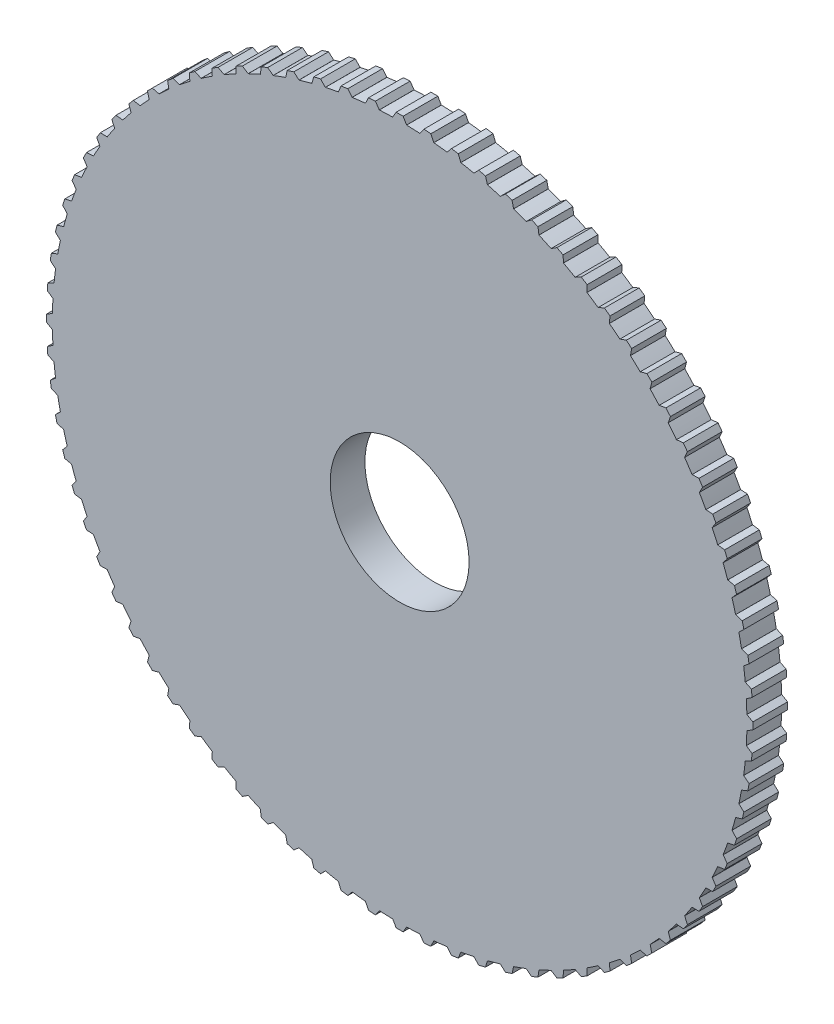
from build123d import *

# Parameters (mm, degrees)
SKETCH1_R           = 20
BOSS_EXTRUDE1_DEPTH = 10


with BuildPart() as part:
    # Sketch1 → Boss-Extrude1 (new body)
    with BuildSketch(Plane.XY):
        with BuildLine():
            Line((-1e-09, 101.7), (0.999999999, 101.7))
            Line((0.999999999, 101.7), (1.999999999, 100))
            Line((1.999999999, 100), (1.999600119, 99.980005998))
            ThreePointArc((1.999600119, 99.980005998), (3.925981575, 99.922903624), (5.85090484, 99.828687823))
            Line((5.85090484, 99.828687823), (5.852074904, 99.848651565))
            Line((5.852074904, 99.848651565), (6.982372701, 101.464951936))
            Line((6.982372701, 101.464951936), (7.979290034, 101.386492841))
            Line((7.979290034, 101.386492841), (8.976207368, 101.308033745))
            Line((8.976207368, 101.308033745), (9.839744239, 99.534815182))
            Line((9.839744239, 99.534815182), (9.837776881, 99.514914189))
            ThreePointArc((9.837776881, 99.514914189), (11.753739745, 99.306845696), (13.665337028, 99.061892592))
            Line((13.665337028, 99.061892592), (13.668069822, 99.08170299))
            Line((13.668069822, 99.08170299), (14.921696753, 100.604338704))
            Line((14.921696753, 100.604338704), (15.909385094, 100.447904239))
            Line((15.909385094, 100.447904239), (16.897073434, 100.291469774))
            Line((16.897073434, 100.291469774), (17.618823184, 98.45596513))
            Line((17.618823184, 98.45596513), (17.615300476, 98.436279842))
            ThreePointArc((17.615300476, 98.436279842), (19.509032201, 98.078528041), (21.395517868, 97.684347851))
            Line((21.395517868, 97.684347851), (21.399796544, 97.703882768))
            Line((21.399796544, 97.703882768), (22.769023583, 99.123466268))
            Line((22.769023583, 99.123466268), (23.741393503, 98.890020905))
            Line((23.741393503, 98.890020905), (24.713763423, 98.656575541))
            Line((24.713763423, 98.656575541), (25.289276225, 96.770101312))
            Line((25.289276225, 96.770101312), (25.284219887, 96.750753096))
            ThreePointArc((25.284219887, 96.750753096), (27.144044985, 96.245523646), (28.993788226, 95.704546623))
            Line((28.993788226, 95.704546623), (28.999586404, 95.723685618))
            Line((28.999586404, 95.723685618), (30.47597181, 97.031464702))
            Line((30.47597181, 97.031464702), (31.427028327, 96.722447707))
            Line((31.427028327, 96.722447707), (32.378084843, 96.413430713))
            Line((32.378084843, 96.413430713), (32.803812469, 94.487617641))
            Line((32.803812469, 94.487617641), (32.797253674, 94.468725785))
            ThreePointArc((32.797253674, 94.468725785), (34.611705707, 93.819133593), (36.413302238, 93.13469504))
            Line((36.413302238, 93.13469504), (36.42058417, 93.153320116))
            Line((36.42058417, 93.153320116), (37.995025538, 94.341231889))
            Line((37.995025538, 94.341231889), (38.91890507, 93.958548457))
            Line((38.91890507, 93.958548457), (39.842784603, 93.575865024))
            Line((39.842784603, 93.575865024), (40.1161023, 91.622586387))
            Line((40.1161023, 91.622586387), (40.108081486, 91.604267365))
            ThreePointArc((40.108081486, 91.604267365), (41.865973753, 90.814317383), (43.608316133, 89.990637091))
            Line((43.608316133, 89.990637091), (43.617036924, 90.008633419))
            Line((43.617036924, 90.008633419), (45.279827298, 91.06935401))
            Line((45.279827298, 91.06935401), (46.170833822, 90.61536351))
            Line((46.170833822, 90.61536351), (47.061840346, 90.161373011))
            Line((47.061840346, 90.161373011), (47.181063021, 88.19267142))
            Line((47.181063021, 88.19267142), (47.171629639, 88.175038175))
            ThreePointArc((47.171629639, 88.175038175), (48.862124149, 87.249600708), (50.534470258, 86.29175694))
            Line((50.534470258, 86.29175694), (50.544576142, 86.309013565))
            Line((50.544576142, 86.309013565), (52.285463866, 87.23600328))
            Line((52.285463866, 87.23600328), (53.13810403, 86.713504715))
            Line((53.13810403, 86.713504715), (53.990744195, 86.191006151))
            Line((53.990744195, 86.191006151), (53.955136799, 84.219019306))
            Line((53.955136799, 84.219019306), (53.944349008, 84.202180554))
            ThreePointArc((53.944349008, 84.202180554), (55.557023301, 83.146961231), (57.14906257, 82.060859412))
            Line((57.14906257, 82.060859412), (57.160491239, 82.077269943))
            Line((57.160491239, 82.077269943), (58.968743163, 82.864813581))
            Line((58.968743163, 82.864813581), (59.777760157, 82.277028328))
            Line((59.777760157, 82.277028328), (60.586777151, 81.689243076))
            Line((60.586777151, 81.689243076), (60.396559217, 79.726128933))
            Line((60.396559217, 79.726128933), (60.384483528, 79.71018849))
            ThreePointArc((60.384483528, 79.71018849), (61.90939493, 78.531693089), (63.411311906, 77.324029398))
            Line((63.411311906, 77.324029398), (63.423992901, 77.339492657))
            Line((63.423992901, 77.339492657), (65.288460548, 77.98273475))
            Line((65.288460548, 77.98273475), (66.048866514, 77.333286702))
            Line((66.048866514, 77.333286702), (66.80927248, 76.683838654))
            Line((66.80927248, 76.683838654), (66.465616763, 74.741700464))
            Line((66.465616763, 74.741700464), (66.452327627, 74.726756607))
            ThreePointArc((66.452327627, 74.726756607), (67.880074552, 73.432250944), (69.282609419, 72.11047103))
            Line((69.282609419, 72.11047103), (69.296464555, 72.124891682))
            Line((69.296464555, 72.124891682), (71.205652864, 72.619866428))
            Line((71.205652864, 72.619866428), (71.912759645, 71.912759647))
            Line((71.912759645, 71.912759647), (72.619866427, 71.205652866))
            Line((72.619866427, 71.205652866), (72.12489168, 69.296464557))
            Line((72.12489168, 69.296464557), (72.110471028, 69.282609421))
            ThreePointArc((72.110471028, 69.282609421), (73.432250943, 67.880074554), (74.726756605, 66.452327628))
            Line((74.726756605, 66.452327628), (74.741700462, 66.465616765))
            Line((74.741700462, 66.465616765), (76.683838652, 66.809272481))
            Line((76.683838652, 66.809272481), (77.3332867, 66.048866516))
            Line((77.3332867, 66.048866516), (77.982734749, 65.28846055))
            Line((77.982734749, 65.28846055), (77.339492655, 63.423992903))
            Line((77.339492655, 63.423992903), (77.324029396, 63.411311908))
            ThreePointArc((77.324029396, 63.411311908), (78.531693087, 61.909394932), (79.710188488, 60.38448353))
            Line((79.710188488, 60.38448353), (79.726128932, 60.396559219))
            Line((79.726128932, 60.396559219), (81.689243074, 60.586777153))
            Line((81.689243074, 60.586777153), (82.277028327, 59.777760159))
            Line((82.277028327, 59.777760159), (82.864813579, 58.968743165))
            Line((82.864813579, 58.968743165), (82.077269941, 57.160491241))
            Line((82.077269941, 57.160491241), (82.06085941, 57.149062572))
            ThreePointArc((82.06085941, 57.149062572), (83.14696123, 55.557023303), (84.202180553, 53.94434901))
            Line((84.202180553, 53.94434901), (84.219019305, 53.955136801))
            Line((84.219019305, 53.955136801), (86.191006149, 53.990744197))
            Line((86.191006149, 53.990744197), (86.713504714, 53.138104032))
            Line((86.713504714, 53.138104032), (87.236003278, 52.285463868))
            Line((87.236003278, 52.285463868), (86.309013564, 50.544576144))
            Line((86.309013564, 50.544576144), (86.291756938, 50.53447026))
            ThreePointArc((86.291756938, 50.53447026), (87.249600707, 48.862124151), (88.175038174, 47.171629641))
            Line((88.175038174, 47.171629641), (88.192671418, 47.181063023))
            Line((88.192671418, 47.181063023), (90.161373009, 47.061840349))
            Line((90.161373009, 47.061840349), (90.615363509, 46.170833824))
            Line((90.615363509, 46.170833824), (91.069354008, 45.2798273))
            Line((91.069354008, 45.2798273), (90.008633417, 43.617036926))
            Line((90.008633417, 43.617036926), (89.99063709, 43.608316136))
            ThreePointArc((89.99063709, 43.608316136), (90.814317382, 41.865973755), (91.604267364, 40.108081488))
            Line((91.604267364, 40.108081488), (91.622586385, 40.116102302))
            Line((91.622586385, 40.116102302), (93.575865023, 39.842784605))
            Line((93.575865023, 39.842784605), (93.958548455, 38.918905073))
            Line((93.958548455, 38.918905073), (94.341231888, 37.99502554))
            Line((94.341231888, 37.99502554), (93.153320115, 36.420584172))
            Line((93.153320115, 36.420584172), (93.134695039, 36.41330224))
            ThreePointArc((93.134695039, 36.41330224), (93.819133592, 34.611705709), (94.468725784, 32.797253676))
            Line((94.468725784, 32.797253676), (94.48761764, 32.803812471))
            Line((94.48761764, 32.803812471), (96.413430712, 32.378084845))
            Line((96.413430712, 32.378084845), (96.722447706, 31.427028329))
            Line((96.722447706, 31.427028329), (97.0314647, 30.475971813))
            Line((97.0314647, 30.475971813), (95.723685617, 28.999586406))
            Line((95.723685617, 28.999586406), (95.704546622, 28.993788228))
            ThreePointArc((95.704546622, 28.993788228), (96.245523645, 27.144044988), (96.750753096, 25.284219889))
            Line((96.750753096, 25.284219889), (96.770101311, 25.289276227))
            Line((96.770101311, 25.289276227), (98.656575539, 24.713763426))
            Line((98.656575539, 24.713763426), (98.890020903, 23.741393505))
            Line((98.890020903, 23.741393505), (99.123466267, 22.769023585))
            Line((99.123466267, 22.769023585), (97.703882766, 21.399796546))
            Line((97.703882766, 21.399796546), (97.684347851, 21.39551787))
            ThreePointArc((97.684347851, 21.39551787), (98.07852804, 19.509032203), (98.436279842, 17.615300479))
            Line((98.436279842, 17.615300479), (98.455965128, 17.618823186))
            Line((98.455965128, 17.618823186), (100.291469772, 16.897073436))
            Line((100.291469772, 16.897073436), (100.447904237, 15.909385096))
            Line((100.447904237, 15.909385096), (100.604338702, 14.921696755))
            Line((100.604338702, 14.921696755), (99.081702989, 13.668069824))
            Line((99.081702989, 13.668069824), (99.061892592, 13.66533703))
            ThreePointArc((99.061892592, 13.66533703), (99.306845695, 11.753739747), (99.514914189, 9.837776883))
            Line((99.514914189, 9.837776883), (99.534815181, 9.839744241))
            Line((99.534815181, 9.839744241), (101.308033744, 8.97620737))
            Line((101.308033744, 8.97620737), (101.38649284, 7.979290037))
            Line((101.38649284, 7.979290037), (101.464951935, 6.982372703))
            Line((101.464951935, 6.982372703), (99.848651564, 5.852074907))
            Line((99.848651564, 5.852074907), (99.828687823, 5.850904843))
            ThreePointArc((99.828687823, 5.850904843), (99.922903624, 3.925981577), (99.980005998, 1.999600121))
            Line((99.980005998, 1.999600121), (99.999999999, 2.000000001))
            Line((99.999999999, 2.000000001), (101.699999999, 1.000000001))
            Line((101.699999999, 1.000000001), (101.699999999, 1e-09))
            Line((101.699999999, 1e-09), (101.699999999, -0.999999999))
            Line((101.699999999, -0.999999999), (99.999999999, -1.999999999))
            Line((99.999999999, -1.999999999), (99.980005998, -1.999600119))
            ThreePointArc((99.980005998, -1.999600119), (99.922903624, -3.925981575), (99.828687823, -5.85090484))
            Line((99.828687823, -5.85090484), (99.848651564, -5.852074904))
            Line((99.848651564, -5.852074904), (101.464951935, -6.9823727))
            Line((101.464951935, -6.9823727), (101.38649284, -7.979290034))
            Line((101.38649284, -7.979290034), (101.308033744, -8.976207368))
            Line((101.308033744, -8.976207368), (99.534815181, -9.839744239))
            Line((99.534815181, -9.839744239), (99.514914189, -9.83777688))
            ThreePointArc((99.514914189, -9.83777688), (99.306845696, -11.753739745), (99.061892592, -13.665337027))
            Line((99.061892592, -13.665337027), (99.081702989, -13.668069821))
            Line((99.081702989, -13.668069821), (100.604338703, -14.921696753))
            Line((100.604338703, -14.921696753), (100.447904238, -15.909385093))
            Line((100.447904238, -15.909385093), (100.291469773, -16.897073434))
            Line((100.291469773, -16.897073434), (98.455965129, -17.618823184))
            Line((98.455965129, -17.618823184), (98.436279842, -17.615300476))
            ThreePointArc((98.436279842, -17.615300476), (98.078528041, -19.5090322), (97.684347851, -21.395517868))
            Line((97.684347851, -21.395517868), (97.703882767, -21.399796543))
            Line((97.703882767, -21.399796543), (99.123466267, -22.769023582))
            Line((99.123466267, -22.769023582), (98.890020904, -23.741393503))
            Line((98.890020904, -23.741393503), (98.65657554, -24.713763423))
            Line((98.65657554, -24.713763423), (96.770101311, -25.289276225))
            Line((96.770101311, -25.289276225), (96.750753096, -25.284219887))
            ThreePointArc((96.750753096, -25.284219887), (96.245523646, -27.144044985), (95.704546623, -28.993788226))
            Line((95.704546623, -28.993788226), (95.723685617, -28.999586403))
            Line((95.723685617, -28.999586403), (97.031464701, -30.47597181))
            Line((97.031464701, -30.47597181), (96.722447706, -31.427028326))
            Line((96.722447706, -31.427028326), (96.413430712, -32.378084843))
            Line((96.413430712, -32.378084843), (94.48761764, -32.803812469))
            Line((94.48761764, -32.803812469), (94.468725785, -32.797253674))
            ThreePointArc((94.468725785, -32.797253674), (93.819133593, -34.611705707), (93.13469504, -36.413302238))
            Line((93.13469504, -36.413302238), (93.153320115, -36.42058417))
            Line((93.153320115, -36.42058417), (94.341231888, -37.995025538))
            Line((94.341231888, -37.995025538), (93.958548456, -38.91890507))
            Line((93.958548456, -38.91890507), (93.575865023, -39.842784603))
            Line((93.575865023, -39.842784603), (91.622586386, -40.1161023))
            Line((91.622586386, -40.1161023), (91.604267365, -40.108081486))
            ThreePointArc((91.604267365, -40.108081486), (90.814317383, -41.865973753), (89.990637091, -43.608316133))
            Line((89.990637091, -43.608316133), (90.008633418, -43.617036924))
            Line((90.008633418, -43.617036924), (91.069354009, -45.279827298))
            Line((91.069354009, -45.279827298), (90.615363509, -46.170833822))
            Line((90.615363509, -46.170833822), (90.16137301, -47.061840346))
            Line((90.16137301, -47.061840346), (88.192671419, -47.181063021))
            Line((88.192671419, -47.181063021), (88.175038175, -47.171629639))
            ThreePointArc((88.175038175, -47.171629639), (87.249600708, -48.862124149), (86.291756939, -50.534470258))
            Line((86.291756939, -50.534470258), (86.309013564, -50.544576141))
            Line((86.309013564, -50.544576141), (87.236003279, -52.285463866))
            Line((87.236003279, -52.285463866), (86.713504714, -53.13810403))
            Line((86.713504714, -53.13810403), (86.19100615, -53.990744194))
            Line((86.19100615, -53.990744194), (84.219019305, -53.955136799))
            Line((84.219019305, -53.955136799), (84.202180554, -53.944349008))
            ThreePointArc((84.202180554, -53.944349008), (83.146961231, -55.557023301), (82.060859412, -57.14906257))
            Line((82.060859412, -57.14906257), (82.077269942, -57.160491239))
            Line((82.077269942, -57.160491239), (82.86481358, -58.968743162))
            Line((82.86481358, -58.968743162), (82.277028327, -59.777760157))
            Line((82.277028327, -59.777760157), (81.689243075, -60.586777151))
            Line((81.689243075, -60.586777151), (79.726128932, -60.396559216))
            Line((79.726128932, -60.396559216), (79.71018849, -60.384483528))
            ThreePointArc((79.71018849, -60.384483528), (78.531693089, -61.90939493), (77.324029398, -63.411311907))
            Line((77.324029398, -63.411311907), (77.339492656, -63.4239929))
            Line((77.339492656, -63.4239929), (77.982734749, -65.288460548))
            Line((77.982734749, -65.288460548), (77.333286701, -66.048866514))
            Line((77.333286701, -66.048866514), (76.683838653, -66.809272479))
            Line((76.683838653, -66.809272479), (74.741700463, -66.465616763))
            Line((74.741700463, -66.465616763), (74.726756607, -66.452327627))
            ThreePointArc((74.726756607, -66.452327627), (73.432250944, -67.880074553), (72.110471029, -69.282609419))
            Line((72.110471029, -69.282609419), (72.124891681, -69.296464555))
            Line((72.124891681, -69.296464555), (72.619866428, -71.205652864))
            Line((72.619866428, -71.205652864), (71.912759646, -71.912759645))
            Line((71.912759646, -71.912759645), (71.205652865, -72.619866426))
            Line((71.205652865, -72.619866426), (69.296464556, -72.124891679))
            Line((69.296464556, -72.124891679), (69.28260942, -72.110471028))
            ThreePointArc((69.28260942, -72.110471028), (67.880074554, -73.432250943), (66.452327628, -74.726756606))
            Line((66.452327628, -74.726756606), (66.465616764, -74.741700462))
            Line((66.465616764, -74.741700462), (66.809272481, -76.683838652))
            Line((66.809272481, -76.683838652), (66.048866515, -77.3332867))
            Line((66.048866515, -77.3332867), (65.288460549, -77.982734748))
            Line((65.288460549, -77.982734748), (63.423992902, -77.339492655))
            Line((63.423992902, -77.339492655), (63.411311908, -77.324029396))
            ThreePointArc((63.411311908, -77.324029396), (61.909394932, -78.531693088), (60.384483529, -79.710188489))
            Line((60.384483529, -79.710188489), (60.396559218, -79.726128931))
            Line((60.396559218, -79.726128931), (60.586777152, -81.689243074))
            Line((60.586777152, -81.689243074), (59.777760158, -82.277028326))
            Line((59.777760158, -82.277028326), (58.968743164, -82.864813579))
            Line((58.968743164, -82.864813579), (57.16049124, -82.077269941))
            Line((57.16049124, -82.077269941), (57.149062571, -82.060859411))
            ThreePointArc((57.149062571, -82.060859411), (55.557023303, -83.14696123), (53.94434901, -84.202180553))
            Line((53.94434901, -84.202180553), (53.9551368, -84.219019304))
            Line((53.9551368, -84.219019304), (53.990744196, -86.191006149))
            Line((53.990744196, -86.191006149), (53.138104031, -86.713504713))
            Line((53.138104031, -86.713504713), (52.285463867, -87.236003278))
            Line((52.285463867, -87.236003278), (50.544576143, -86.309013563))
            Line((50.544576143, -86.309013563), (50.53447026, -86.291756939))
            ThreePointArc((50.53447026, -86.291756939), (48.86212415, -87.249600707), (47.17162964, -88.175038175))
            Line((47.17162964, -88.175038175), (47.181063022, -88.192671418))
            Line((47.181063022, -88.192671418), (47.061840348, -90.161373009))
            Line((47.061840348, -90.161373009), (46.170833823, -90.615363508))
            Line((46.170833823, -90.615363508), (45.279827299, -91.069354008))
            Line((45.279827299, -91.069354008), (43.617036926, -90.008633417))
            Line((43.617036926, -90.008633417), (43.608316135, -89.99063709))
            ThreePointArc((43.608316135, -89.99063709), (41.865973754, -90.814317382), (40.108081488, -91.604267364))
            Line((40.108081488, -91.604267364), (40.116102302, -91.622586385))
            Line((40.116102302, -91.622586385), (39.842784604, -93.575865023))
            Line((39.842784604, -93.575865023), (38.918905072, -93.958548455))
            Line((38.918905072, -93.958548455), (37.995025539, -94.341231887))
            Line((37.995025539, -94.341231887), (36.420584171, -93.153320114))
            Line((36.420584171, -93.153320114), (36.41330224, -93.134695039))
            ThreePointArc((36.41330224, -93.134695039), (34.611705708, -93.819133592), (32.797253676, -94.468725784))
            Line((32.797253676, -94.468725784), (32.80381247, -94.487617639))
            Line((32.80381247, -94.487617639), (32.378084844, -96.413430711))
            Line((32.378084844, -96.413430711), (31.427028328, -96.722447706))
            Line((31.427028328, -96.722447706), (30.475971812, -97.0314647))
            Line((30.475971812, -97.0314647), (28.999586405, -95.723685617))
            Line((28.999586405, -95.723685617), (28.993788227, -95.704546623))
            ThreePointArc((28.993788227, -95.704546623), (27.144044987, -96.245523645), (25.284219888, -96.750753096))
            Line((25.284219888, -96.750753096), (25.289276227, -96.770101311))
            Line((25.289276227, -96.770101311), (24.713763425, -98.656575539))
            Line((24.713763425, -98.656575539), (23.741393504, -98.890020903))
            Line((23.741393504, -98.890020903), (22.769023584, -99.123466267))
            Line((22.769023584, -99.123466267), (21.399796545, -97.703882766))
            Line((21.399796545, -97.703882766), (21.395517869, -97.684347851))
            ThreePointArc((21.395517869, -97.684347851), (19.509032202, -98.07852804), (17.615300478, -98.436279842))
            Line((17.615300478, -98.436279842), (17.618823185, -98.455965128))
            Line((17.618823185, -98.455965128), (16.897073435, -100.291469772))
            Line((16.897073435, -100.291469772), (15.909385095, -100.447904237))
            Line((15.909385095, -100.447904237), (14.921696754, -100.604338702))
            Line((14.921696754, -100.604338702), (13.668069823, -99.081702988))
            Line((13.668069823, -99.081702988), (13.665337029, -99.061892592))
            ThreePointArc((13.665337029, -99.061892592), (11.753739746, -99.306845695), (9.837776882, -99.514914189))
            Line((9.837776882, -99.514914189), (9.83974424, -99.534815181))
            Line((9.83974424, -99.534815181), (8.97620737, -101.308033744))
            Line((8.97620737, -101.308033744), (7.979290036, -101.386492839))
            Line((7.979290036, -101.386492839), (6.982372702, -101.464951935))
            Line((6.982372702, -101.464951935), (5.852074906, -99.848651563))
            Line((5.852074906, -99.848651563), (5.850904842, -99.828687823))
            ThreePointArc((5.850904842, -99.828687823), (3.925981576, -99.922903624), (1.99960012, -99.980005998))
            Line((1.99960012, -99.980005998), (2, -99.999999999))
            Line((2, -99.999999999), (1, -101.699999999))
            Line((1, -101.699999999), (0, -101.699999999))
            Line((0, -101.699999999), (-1, -101.699999999))
            Line((-1, -101.699999999), (-2, -99.999999999))
            Line((-2, -99.999999999), (-1.99960012, -99.980005998))
            ThreePointArc((-1.99960012, -99.980005998), (-3.925981576, -99.922903624), (-5.850904841, -99.828687823))
            Line((-5.850904841, -99.828687823), (-5.852074905, -99.848651564))
            Line((-5.852074905, -99.848651564), (-6.982372701, -101.464951935))
            Line((-6.982372701, -101.464951935), (-7.979290035, -101.386492839))
            Line((-7.979290035, -101.386492839), (-8.976207369, -101.308033744))
            Line((-8.976207369, -101.308033744), (-9.83974424, -99.534815181))
            Line((-9.83974424, -99.534815181), (-9.837776881, -99.514914189))
            ThreePointArc((-9.837776881, -99.514914189), (-11.753739746, -99.306845696), (-13.665337028, -99.061892592))
            Line((-13.665337028, -99.061892592), (-13.668069822, -99.081702988))
            Line((-13.668069822, -99.081702988), (-14.921696754, -100.604338702))
            Line((-14.921696754, -100.604338702), (-15.909385094, -100.447904237))
            Line((-15.909385094, -100.447904237), (-16.897073435, -100.291469772))
            Line((-16.897073435, -100.291469772), (-17.618823185, -98.455965128))
            Line((-17.618823185, -98.455965128), (-17.615300477, -98.436279842))
            ThreePointArc((-17.615300477, -98.436279842), (-19.509032201, -98.07852804), (-21.395517869, -97.684347851))
            Line((-21.395517869, -97.684347851), (-21.399796544, -97.703882766))
            Line((-21.399796544, -97.703882766), (-22.769023583, -99.123466267))
            Line((-22.769023583, -99.123466267), (-23.741393504, -98.890020903))
            Line((-23.741393504, -98.890020903), (-24.713763424, -98.656575539))
            Line((-24.713763424, -98.656575539), (-25.289276226, -96.770101311))
            Line((-25.289276226, -96.770101311), (-25.284219888, -96.750753096))
            ThreePointArc((-25.284219888, -96.750753096), (-27.144044986, -96.245523645), (-28.993788227, -95.704546623))
            Line((-28.993788227, -95.704546623), (-28.999586404, -95.723685617))
            Line((-28.999586404, -95.723685617), (-30.475971811, -97.031464701))
            Line((-30.475971811, -97.031464701), (-31.427028327, -96.722447706))
            Line((-31.427028327, -96.722447706), (-32.378084844, -96.413430712))
            Line((-32.378084844, -96.413430712), (-32.80381247, -94.48761764))
            Line((-32.80381247, -94.48761764), (-32.797253675, -94.468725785))
            ThreePointArc((-32.797253675, -94.468725785), (-34.611705708, -93.819133592), (-36.413302239, -93.134695039))
            Line((-36.413302239, -93.134695039), (-36.420584171, -93.153320115))
            Line((-36.420584171, -93.153320115), (-37.995025539, -94.341231888))
            Line((-37.995025539, -94.341231888), (-38.918905071, -93.958548455))
            Line((-38.918905071, -93.958548455), (-39.842784604, -93.575865023))
            Line((-39.842784604, -93.575865023), (-40.116102301, -91.622586385))
            Line((-40.116102301, -91.622586385), (-40.108081487, -91.604267365))
            ThreePointArc((-40.108081487, -91.604267365), (-41.865973754, -90.814317383), (-43.608316134, -89.99063709))
            Line((-43.608316134, -89.99063709), (-43.617036925, -90.008633417))
            Line((-43.617036925, -90.008633417), (-45.279827299, -91.069354009))
            Line((-45.279827299, -91.069354009), (-46.170833823, -90.615363509))
            Line((-46.170833823, -90.615363509), (-47.061840347, -90.161373009))
            Line((-47.061840347, -90.161373009), (-47.181063022, -88.192671418))
            Line((-47.181063022, -88.192671418), (-47.17162964, -88.175038175))
            ThreePointArc((-47.17162964, -88.175038175), (-48.86212415, -87.249600707), (-50.534470259, -86.291756939))
            Line((-50.534470259, -86.291756939), (-50.544576142, -86.309013564))
            Line((-50.544576142, -86.309013564), (-52.285463867, -87.236003279))
            Line((-52.285463867, -87.236003279), (-53.138104031, -86.713504714))
            Line((-53.138104031, -86.713504714), (-53.990744195, -86.191006149))
            Line((-53.990744195, -86.191006149), (-53.9551368, -84.219019305))
            Line((-53.9551368, -84.219019305), (-53.944349009, -84.202180554))
            ThreePointArc((-53.944349009, -84.202180554), (-55.557023302, -83.14696123), (-57.149062571, -82.060859411))
            Line((-57.149062571, -82.060859411), (-57.16049124, -82.077269941))
            Line((-57.16049124, -82.077269941), (-58.968743163, -82.864813579))
            Line((-58.968743163, -82.864813579), (-59.777760158, -82.277028327))
            Line((-59.777760158, -82.277028327), (-60.586777152, -81.689243075))
            Line((-60.586777152, -81.689243075), (-60.396559217, -79.726128932))
            Line((-60.396559217, -79.726128932), (-60.384483529, -79.710188489))
            ThreePointArc((-60.384483529, -79.710188489), (-61.909394931, -78.531693088), (-63.411311907, -77.324029397))
            Line((-63.411311907, -77.324029397), (-63.423992901, -77.339492656))
            Line((-63.423992901, -77.339492656), (-65.288460549, -77.982734749))
            Line((-65.288460549, -77.982734749), (-66.048866515, -77.333286701))
            Line((-66.048866515, -77.333286701), (-66.80927248, -76.683838652))
            Line((-66.80927248, -76.683838652), (-66.465616764, -74.741700463))
            Line((-66.465616764, -74.741700463), (-66.452327628, -74.726756606))
            ThreePointArc((-66.452327628, -74.726756606), (-67.880074553, -73.432250944), (-69.28260942, -72.110471029))
            Line((-69.28260942, -72.110471029), (-69.296464556, -72.12489168))
            Line((-69.296464556, -72.12489168), (-71.205652865, -72.619866427))
            Line((-71.205652865, -72.619866427), (-71.912759646, -71.912759646))
            Line((-71.912759646, -71.912759646), (-72.619866427, -71.205652865))
            Line((-72.619866427, -71.205652865), (-72.12489168, -69.296464556))
            Line((-72.12489168, -69.296464556), (-72.110471029, -69.28260942))
            ThreePointArc((-72.110471029, -69.28260942), (-73.432250944, -67.880074553), (-74.726756606, -66.452327627))
            Line((-74.726756606, -66.452327627), (-74.741700463, -66.465616764))
            Line((-74.741700463, -66.465616764), (-76.683838653, -66.80927248))
            Line((-76.683838653, -66.80927248), (-77.333286701, -66.048866515))
            Line((-77.333286701, -66.048866515), (-77.982734749, -65.288460549))
            Line((-77.982734749, -65.288460549), (-77.339492656, -63.423992901))
            Line((-77.339492656, -63.423992901), (-77.324029397, -63.411311907))
            ThreePointArc((-77.324029397, -63.411311907), (-78.531693088, -61.909394931), (-79.710188489, -60.384483529))
            Line((-79.710188489, -60.384483529), (-79.726128932, -60.396559217))
            Line((-79.726128932, -60.396559217), (-81.689243075, -60.586777152))
            Line((-81.689243075, -60.586777152), (-82.277028327, -59.777760158))
            Line((-82.277028327, -59.777760158), (-82.86481358, -58.968743163))
            Line((-82.86481358, -58.968743163), (-82.077269942, -57.16049124))
            Line((-82.077269942, -57.16049124), (-82.060859411, -57.149062571))
            ThreePointArc((-82.060859411, -57.149062571), (-83.14696123, -55.557023302), (-84.202180554, -53.944349009))
            Line((-84.202180554, -53.944349009), (-84.219019305, -53.9551368))
            Line((-84.219019305, -53.9551368), (-86.19100615, -53.990744196))
            Line((-86.19100615, -53.990744196), (-86.713504714, -53.138104031))
            Line((-86.713504714, -53.138104031), (-87.236003279, -52.285463867))
            Line((-87.236003279, -52.285463867), (-86.309013564, -50.544576142))
            Line((-86.309013564, -50.544576142), (-86.291756939, -50.534470259))
            ThreePointArc((-86.291756939, -50.534470259), (-87.249600707, -48.86212415), (-88.175038175, -47.17162964))
            Line((-88.175038175, -47.17162964), (-88.192671419, -47.181063022))
            Line((-88.192671419, -47.181063022), (-90.16137301, -47.061840347))
            Line((-90.16137301, -47.061840347), (-90.615363509, -46.170833823))
            Line((-90.615363509, -46.170833823), (-91.069354009, -45.279827299))
            Line((-91.069354009, -45.279827299), (-90.008633418, -43.617036925))
            Line((-90.008633418, -43.617036925), (-89.99063709, -43.608316134))
            ThreePointArc((-89.99063709, -43.608316134), (-90.814317383, -41.865973754), (-91.604267365, -40.108081487))
            Line((-91.604267365, -40.108081487), (-91.622586386, -40.116102301))
            Line((-91.622586386, -40.116102301), (-93.575865024, -39.842784604))
            Line((-93.575865024, -39.842784604), (-93.958548456, -38.918905071))
            Line((-93.958548456, -38.918905071), (-94.341231888, -37.995025539))
            Line((-94.341231888, -37.995025539), (-93.153320115, -36.420584171))
            Line((-93.153320115, -36.420584171), (-93.134695039, -36.413302239))
            ThreePointArc((-93.134695039, -36.413302239), (-93.819133592, -34.611705708), (-94.468725785, -32.797253675))
            Line((-94.468725785, -32.797253675), (-94.48761764, -32.80381247))
            Line((-94.48761764, -32.80381247), (-96.413430712, -32.378084844))
            Line((-96.413430712, -32.378084844), (-96.722447707, -31.427028328))
            Line((-96.722447707, -31.427028328), (-97.031464701, -30.475971811))
            Line((-97.031464701, -30.475971811), (-95.723685618, -28.999586405))
            Line((-95.723685618, -28.999586405), (-95.704546623, -28.993788227))
            ThreePointArc((-95.704546623, -28.993788227), (-96.245523645, -27.144044986), (-96.750753096, -25.284219888))
            Line((-96.750753096, -25.284219888), (-96.770101312, -25.289276226))
            Line((-96.770101312, -25.289276226), (-98.65657554, -24.713763424))
            Line((-98.65657554, -24.713763424), (-98.890020904, -23.741393504))
            Line((-98.890020904, -23.741393504), (-99.123466268, -22.769023584))
            Line((-99.123466268, -22.769023584), (-97.703882767, -21.399796545))
            Line((-97.703882767, -21.399796545), (-97.684347851, -21.395517869))
            ThreePointArc((-97.684347851, -21.395517869), (-98.07852804, -19.509032202), (-98.436279842, -17.615300477))
            Line((-98.436279842, -17.615300477), (-98.455965129, -17.618823185))
            Line((-98.455965129, -17.618823185), (-100.291469773, -16.897073435))
            Line((-100.291469773, -16.897073435), (-100.447904238, -15.909385094))
            Line((-100.447904238, -15.909385094), (-100.604338703, -14.921696754))
            Line((-100.604338703, -14.921696754), (-99.081702989, -13.668069823))
            Line((-99.081702989, -13.668069823), (-99.061892592, -13.665337029))
            ThreePointArc((-99.061892592, -13.665337029), (-99.306845695, -11.753739746), (-99.514914189, -9.837776882))
            Line((-99.514914189, -9.837776882), (-99.534815181, -9.83974424))
            Line((-99.534815181, -9.83974424), (-101.308033745, -8.976207369))
            Line((-101.308033745, -8.976207369), (-101.38649284, -7.979290035))
            Line((-101.38649284, -7.979290035), (-101.464951936, -6.982372702))
            Line((-101.464951936, -6.982372702), (-99.848651564, -5.852074905))
            Line((-99.848651564, -5.852074905), (-99.828687823, -5.850904841))
            ThreePointArc((-99.828687823, -5.850904841), (-99.922903624, -3.925981576), (-99.980005998, -1.99960012))
            Line((-99.980005998, -1.99960012), (-100, -2))
            Line((-100, -2), (-101.7, -1))
            Line((-101.7, -1), (-101.7, 0))
            Line((-101.7, 0), (-101.7, 1))
            Line((-101.7, 1), (-100, 2))
            Line((-100, 2), (-99.980005998, 1.99960012))
            ThreePointArc((-99.980005998, 1.99960012), (-99.922903624, 3.925981576), (-99.828687823, 5.850904841))
            Line((-99.828687823, 5.850904841), (-99.848651565, 5.852074905))
            Line((-99.848651565, 5.852074905), (-101.464951936, 6.982372702))
            Line((-101.464951936, 6.982372702), (-101.38649284, 7.979290035))
            Line((-101.38649284, 7.979290035), (-101.308033745, 8.976207369))
            Line((-101.308033745, 8.976207369), (-99.534815182, 9.83974424))
            Line((-99.534815182, 9.83974424), (-99.514914189, 9.837776882))
            ThreePointArc((-99.514914189, 9.837776882), (-99.306845695, 11.753739746), (-99.061892592, 13.665337029))
            Line((-99.061892592, 13.665337029), (-99.081702989, 13.668069823))
            Line((-99.081702989, 13.668069823), (-100.604338703, 14.921696754))
            Line((-100.604338703, 14.921696754), (-100.447904238, 15.909385094))
            Line((-100.447904238, 15.909385094), (-100.291469773, 16.897073435))
            Line((-100.291469773, 16.897073435), (-98.455965129, 17.618823185))
            Line((-98.455965129, 17.618823185), (-98.436279842, 17.615300477))
            ThreePointArc((-98.436279842, 17.615300477), (-98.07852804, 19.509032202), (-97.684347851, 21.395517869))
            Line((-97.684347851, 21.395517869), (-97.703882767, 21.399796545))
            Line((-97.703882767, 21.399796545), (-99.123466268, 22.769023584))
            Line((-99.123466268, 22.769023584), (-98.890020904, 23.741393504))
            Line((-98.890020904, 23.741393504), (-98.65657554, 24.713763424))
            Line((-98.65657554, 24.713763424), (-96.770101312, 25.289276226))
            Line((-96.770101312, 25.289276226), (-96.750753096, 25.284219888))
            ThreePointArc((-96.750753096, 25.284219888), (-96.245523645, 27.144044986), (-95.704546623, 28.993788227))
            Line((-95.704546623, 28.993788227), (-95.723685618, 28.999586405))
            Line((-95.723685618, 28.999586405), (-97.031464702, 30.475971811))
            Line((-97.031464702, 30.475971811), (-96.722447707, 31.427028328))
            Line((-96.722447707, 31.427028328), (-96.413430713, 32.378084844))
            Line((-96.413430713, 32.378084844), (-94.487617641, 32.80381247))
            Line((-94.487617641, 32.80381247), (-94.468725785, 32.797253675))
            ThreePointArc((-94.468725785, 32.797253675), (-93.819133592, 34.611705708), (-93.134695039, 36.413302239))
            Line((-93.134695039, 36.413302239), (-93.153320116, 36.420584171))
            Line((-93.153320116, 36.420584171), (-94.341231889, 37.995025539))
            Line((-94.341231889, 37.995025539), (-93.958548456, 38.918905071))
            Line((-93.958548456, 38.918905071), (-93.575865024, 39.842784604))
            Line((-93.575865024, 39.842784604), (-91.622586386, 40.116102301))
            Line((-91.622586386, 40.116102301), (-91.604267365, 40.108081487))
            ThreePointArc((-91.604267365, 40.108081487), (-90.814317383, 41.865973754), (-89.99063709, 43.608316134))
            Line((-89.99063709, 43.608316134), (-90.008633418, 43.617036925))
            Line((-90.008633418, 43.617036925), (-91.06935401, 45.279827299))
            Line((-91.06935401, 45.279827299), (-90.61536351, 46.170833823))
            Line((-90.61536351, 46.170833823), (-90.16137301, 47.061840347))
            Line((-90.16137301, 47.061840347), (-88.192671419, 47.181063022))
            Line((-88.192671419, 47.181063022), (-88.175038175, 47.171629639))
            ThreePointArc((-88.175038175, 47.171629639), (-87.249600707, 48.862124149), (-86.291756939, 50.534470259))
            Line((-86.291756939, 50.534470259), (-86.309013565, 50.544576143))
            Line((-86.309013565, 50.544576143), (-87.23600328, 52.285463867))
            Line((-87.23600328, 52.285463867), (-86.713504715, 53.138104031))
            Line((-86.713504715, 53.138104031), (-86.19100615, 53.990744196))
            Line((-86.19100615, 53.990744196), (-84.219019306, 53.9551368))
            Line((-84.219019306, 53.9551368), (-84.202180554, 53.944349009))
            ThreePointArc((-84.202180554, 53.944349009), (-83.14696123, 55.557023302), (-82.060859411, 57.14906257))
            Line((-82.060859411, 57.14906257), (-82.077269942, 57.16049124))
            Line((-82.077269942, 57.16049124), (-82.86481358, 58.968743164))
            Line((-82.86481358, 58.968743164), (-82.277028328, 59.777760158))
            Line((-82.277028328, 59.777760158), (-81.689243076, 60.586777152))
            Line((-81.689243076, 60.586777152), (-79.726128933, 60.396559218))
            Line((-79.726128933, 60.396559218), (-79.710188489, 60.384483528))
            ThreePointArc((-79.710188489, 60.384483528), (-78.531693088, 61.909394931), (-77.324029397, 63.411311907))
            Line((-77.324029397, 63.411311907), (-77.339492657, 63.423992902))
            Line((-77.339492657, 63.423992902), (-77.98273475, 65.288460549))
            Line((-77.98273475, 65.288460549), (-77.333286702, 66.048866515))
            Line((-77.333286702, 66.048866515), (-76.683838653, 66.809272481))
            Line((-76.683838653, 66.809272481), (-74.741700464, 66.465616764))
            Line((-74.741700464, 66.465616764), (-74.726756607, 66.452327627))
            ThreePointArc((-74.726756607, 66.452327627), (-73.432250944, 67.880074553), (-72.110471029, 69.282609419))
            Line((-72.110471029, 69.282609419), (-72.124891681, 69.296464556))
            Line((-72.124891681, 69.296464556), (-72.619866428, 71.205652865))
            Line((-72.619866428, 71.205652865), (-71.912759647, 71.912759646))
            Line((-71.912759647, 71.912759646), (-71.205652866, 72.619866428))
            Line((-71.205652866, 72.619866428), (-69.296464557, 72.124891681))
            Line((-69.296464557, 72.124891681), (-69.28260942, 72.110471028))
            ThreePointArc((-69.28260942, 72.110471028), (-67.880074554, 73.432250943), (-66.452327628, 74.726756606))
            Line((-66.452327628, 74.726756606), (-66.465616765, 74.741700463))
            Line((-66.465616765, 74.741700463), (-66.809272481, 76.683838653))
            Line((-66.809272481, 76.683838653), (-66.048866516, 77.333286701))
            Line((-66.048866516, 77.333286701), (-65.28846055, 77.98273475))
            Line((-65.28846055, 77.98273475), (-63.423992902, 77.339492656))
            Line((-63.423992902, 77.339492656), (-63.411311908, 77.324029397))
            ThreePointArc((-63.411311908, 77.324029397), (-61.909394931, 78.531693088), (-60.384483529, 79.710188489))
            Line((-60.384483529, 79.710188489), (-60.396559218, 79.726128933))
            Line((-60.396559218, 79.726128933), (-60.586777153, 81.689243075))
            Line((-60.586777153, 81.689243075), (-59.777760159, 82.277028328))
            Line((-59.777760159, 82.277028328), (-58.968743164, 82.86481358))
            Line((-58.968743164, 82.86481358), (-57.160491241, 82.077269942))
            Line((-57.160491241, 82.077269942), (-57.149062571, 82.060859411))
            ThreePointArc((-57.149062571, 82.060859411), (-55.557023302, 83.14696123), (-53.94434901, 84.202180553))
            Line((-53.94434901, 84.202180553), (-53.955136801, 84.219019306))
            Line((-53.955136801, 84.219019306), (-53.990744197, 86.19100615))
            Line((-53.990744197, 86.19100615), (-53.138104032, 86.713504715))
            Line((-53.138104032, 86.713504715), (-52.285463868, 87.236003279))
            Line((-52.285463868, 87.236003279), (-50.544576143, 86.309013565))
            Line((-50.544576143, 86.309013565), (-50.53447026, 86.291756939))
            ThreePointArc((-50.53447026, 86.291756939), (-48.86212415, 87.249600707), (-47.17162964, 88.175038175))
            Line((-47.17162964, 88.175038175), (-47.181063023, 88.192671419))
            Line((-47.181063023, 88.192671419), (-47.061840348, 90.16137301))
            Line((-47.061840348, 90.16137301), (-46.170833824, 90.61536351))
            Line((-46.170833824, 90.61536351), (-45.2798273, 91.069354009))
            Line((-45.2798273, 91.069354009), (-43.617036926, 90.008633418))
            Line((-43.617036926, 90.008633418), (-43.608316135, 89.99063709))
            ThreePointArc((-43.608316135, 89.99063709), (-41.865973754, 90.814317382), (-40.108081488, 91.604267364))
            Line((-40.108081488, 91.604267364), (-40.116102302, 91.622586386))
            Line((-40.116102302, 91.622586386), (-39.842784605, 93.575865024))
            Line((-39.842784605, 93.575865024), (-38.918905072, 93.958548456))
            Line((-38.918905072, 93.958548456), (-37.99502554, 94.341231889))
            Line((-37.99502554, 94.341231889), (-36.420584172, 93.153320116))
            Line((-36.420584172, 93.153320116), (-36.41330224, 93.134695039))
            ThreePointArc((-36.41330224, 93.134695039), (-34.611705708, 93.819133592), (-32.797253676, 94.468725784))
            Line((-32.797253676, 94.468725784), (-32.803812471, 94.487617641))
            Line((-32.803812471, 94.487617641), (-32.378084845, 96.413430713))
            Line((-32.378084845, 96.413430713), (-31.427028329, 96.722447707))
            Line((-31.427028329, 96.722447707), (-30.475971812, 97.031464701))
            Line((-30.475971812, 97.031464701), (-28.999586406, 95.723685618))
            Line((-28.999586406, 95.723685618), (-28.993788228, 95.704546622))
            ThreePointArc((-28.993788228, 95.704546622), (-27.144044987, 96.245523645), (-25.284219889, 96.750753096))
            Line((-25.284219889, 96.750753096), (-25.289276227, 96.770101312))
            Line((-25.289276227, 96.770101312), (-24.713763425, 98.65657554))
            Line((-24.713763425, 98.65657554), (-23.741393505, 98.890020904))
            Line((-23.741393505, 98.890020904), (-22.769023585, 99.123466268))
            Line((-22.769023585, 99.123466268), (-21.399796546, 97.703882767))
            Line((-21.399796546, 97.703882767), (-21.39551787, 97.684347851))
            ThreePointArc((-21.39551787, 97.684347851), (-19.509032202, 98.07852804), (-17.615300478, 98.436279842))
            Line((-17.615300478, 98.436279842), (-17.618823186, 98.455965129))
            Line((-17.618823186, 98.455965129), (-16.897073436, 100.291469773))
            Line((-16.897073436, 100.291469773), (-15.909385095, 100.447904238))
            Line((-15.909385095, 100.447904238), (-14.921696755, 100.604338703))
            Line((-14.921696755, 100.604338703), (-13.668069824, 99.081702989))
            Line((-13.668069824, 99.081702989), (-13.66533703, 99.061892592))
            ThreePointArc((-13.66533703, 99.061892592), (-11.753739747, 99.306845695), (-9.837776883, 99.514914189))
            Line((-9.837776883, 99.514914189), (-9.839744241, 99.534815182))
            Line((-9.839744241, 99.534815182), (-8.97620737, 101.308033745))
            Line((-8.97620737, 101.308033745), (-7.979290036, 101.386492841))
            Line((-7.979290036, 101.386492841), (-6.982372703, 101.464951936))
            Line((-6.982372703, 101.464951936), (-5.852074906, 99.848651565))
            Line((-5.852074906, 99.848651565), (-5.850904842, 99.828687823))
            ThreePointArc((-5.850904842, 99.828687823), (-3.925981577, 99.922903624), (-1.999600121, 99.980005998))
            Line((-1.999600121, 99.980005998), (-2.000000001, 100))
            Line((-2.000000001, 100), (-1.000000001, 101.7))
            Line((-1.000000001, 101.7), (-1e-09, 101.7))
        make_face()
        Circle(SKETCH1_R, mode=Mode.SUBTRACT)
    extrude(amount=BOSS_EXTRUDE1_DEPTH)


solid = part.part
